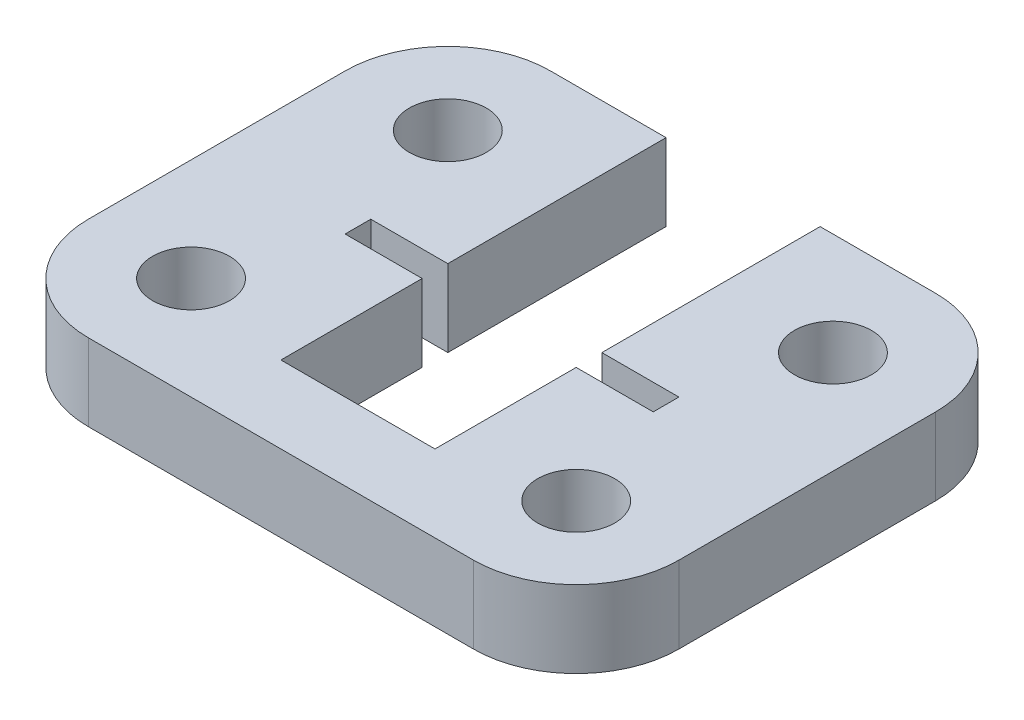
from build123d import *

# Parameters (mm, degrees)
SKETCH1_R           = 1.5
BOSS_EXTRUDE1_DEPTH = 3


with BuildPart() as part:
    # Sketch1 → Boss-Extrude1 (new body)
    with BuildSketch(Plane(origin=(0, 0, 0), x_dir=(1, 0, 0), z_dir=(0, 1, 0))):
        with BuildLine():
            Line((7.951300085, -43.552898009), (7.95129997, -52.052898009))
            Line((7.95129997, -52.052898009), (10.95129997, -52.052898009))
            Line((10.95129997, -52.052898009), (10.95129997, -53.052897806))
            Line((10.95129997, -53.052897806), (7.95129997, -53.052897806))
            Line((7.95129997, -53.052897806), (7.95129997, -58.552897806))
            Line((7.95129997, -58.552897806), (1.95129997, -58.552897806))
            Line((1.95129997, -58.552897806), (1.95129997, -53.052897806))
            Line((1.95129997, -53.052897806), (-1.04870003, -53.052897806))
            Line((-1.04870003, -53.052897806), (-1.04870003, -52.052897806))
            Line((-1.04870003, -52.052897806), (1.95129997, -52.052897806))
            Line((1.95129997, -52.052897806), (1.951300085, -43.552897806))
            Line((1.951300085, -43.552897806), (-2.548699915, -43.552897806))
            ThreePointArc((-2.548699915, -43.552897806), (-5.377127055, -44.724470643), (-6.548699969, -47.552897752))
            Line((-6.548699969, -47.552897752), (-6.548700104, -57.552897752))
            ThreePointArc((-6.548700104, -57.552897752), (-5.377127267, -60.381324893), (-2.548700158, -61.552897806))
            Line((-2.548700158, -61.552897806), (12.451299842, -61.552898009))
            ThreePointArc((12.451299842, -61.552898009), (15.279726982, -60.381325172), (16.451299896, -57.552898064))
            Line((16.451299896, -57.552898064), (16.451300031, -47.552898064))
            ThreePointArc((16.451300031, -47.552898064), (15.279727194, -44.724470923), (12.451300085, -43.552898009))
            Line((12.451300085, -43.552898009), (7.951300085, -43.552898009))
        make_face()
        with Locations((12.451300031, -47.552898009)):
            Circle(SKETCH1_R, mode=Mode.SUBTRACT)
        with Locations((12.451299896, -57.552898009)):
            Circle(SKETCH1_R, mode=Mode.SUBTRACT)
        with Locations((-2.548700104, -57.552897806)):
            Circle(SKETCH1_R, mode=Mode.SUBTRACT)
        with Locations((-2.548699969, -47.552897806)):
            Circle(SKETCH1_R, mode=Mode.SUBTRACT)
    extrude(amount=BOSS_EXTRUDE1_DEPTH)


solid = part.part
